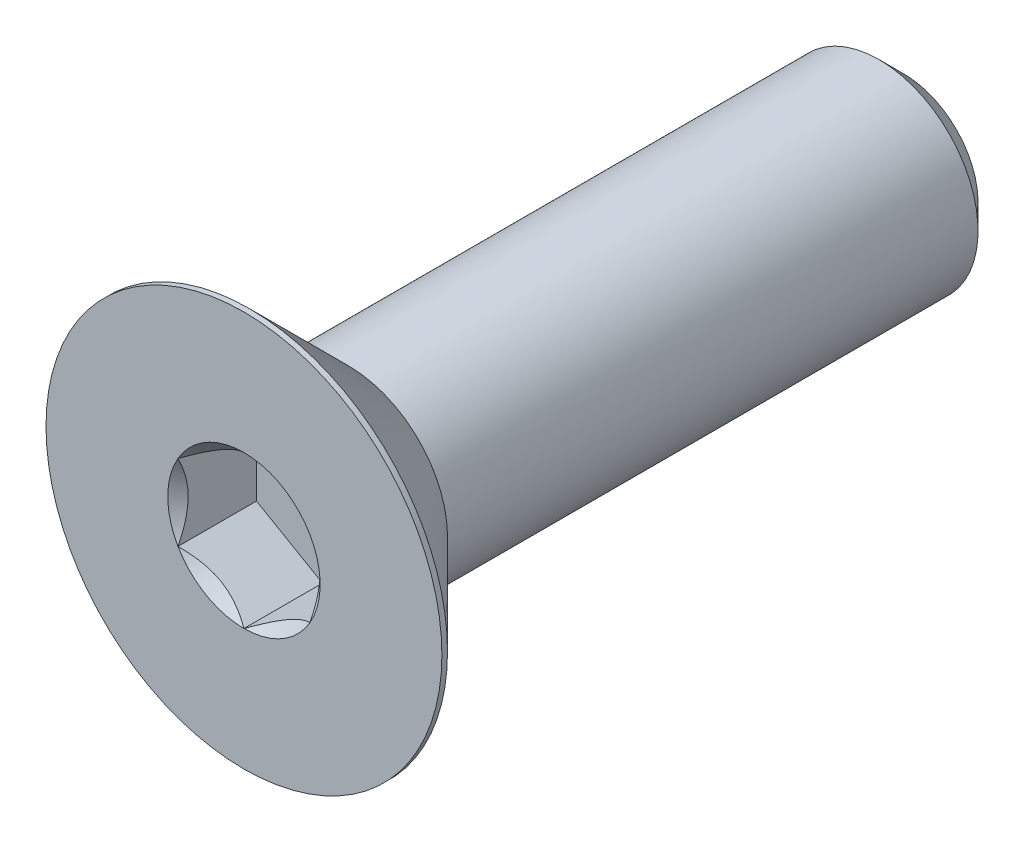
from build123d import *

# Parameters (mm, degrees)
CHAMFER1_SIZE      = 0.375
CUT_EXTRUDE2_DEPTH = 1.19


with BuildPart() as part:
    # Sketch1 → Revolve1 (revolve)
    with BuildSketch(Plane(origin=(0, 0, 0), x_dir=(0, 0, -1), z_dir=(1, 0, 0))):
        Polygon((-3.3, 1.5), (5, 1.5), (5, 0), (-3.81, 0), (-3.81, 1.5), align=None)
    revolve(axis=Axis((0, 0, 3.81), (0, 0, -1)))

    # Chamfer1
    chamfer1_edges = [part.edges().sort_by_distance(p)[0] for p in [
        (0, -1.5, -5),
    ]]
    chamfer(chamfer1_edges, length=CHAMFER1_SIZE)


with BuildPart() as body_2:
    # Sketch7 → Revolve2 (revolve)
    with BuildSketch(Plane(origin=(0, 0, 0), x_dir=(0, 0, -1), z_dir=(1, 0, 0))):
        Polygon((-4.915, 3), (-5, 3), (-5, 0), (-3.3, 0), (-3.3, 1.385), align=None)
    revolve(axis=Axis((0, 0, 5), (0, 0, -1)))

    # Sketch5 → Cut-Extrude2 (cut)
    with BuildSketch(Plane.XY.offset(5)):
        Polygon((1, -0.577350269), (1, 0.577350269), (0, 1.154700538), (-1, 0.577350269), (-1, -0.577350269), (0, -1.154700538), align=None)
    extrude(amount=-CUT_EXTRUDE2_DEPTH, mode=Mode.SUBTRACT)

    # Cut-Extrude3 cone 1 section (through the dimple's axis) → Cut-Extrude3 (revolve, cut)
    with BuildSketch(Plane(origin=(0, 0, 5), x_dir=(0, -1, 0), z_dir=(1, 0, 0))):
        Polygon((0, 0), (1.154700538, 0), (0, 1.154700538), align=None)
    revolve(axis=Axis((0, 0, 5), (0, 0, -1)), mode=Mode.SUBTRACT)


solid = Compound([part.part, body_2.part])
